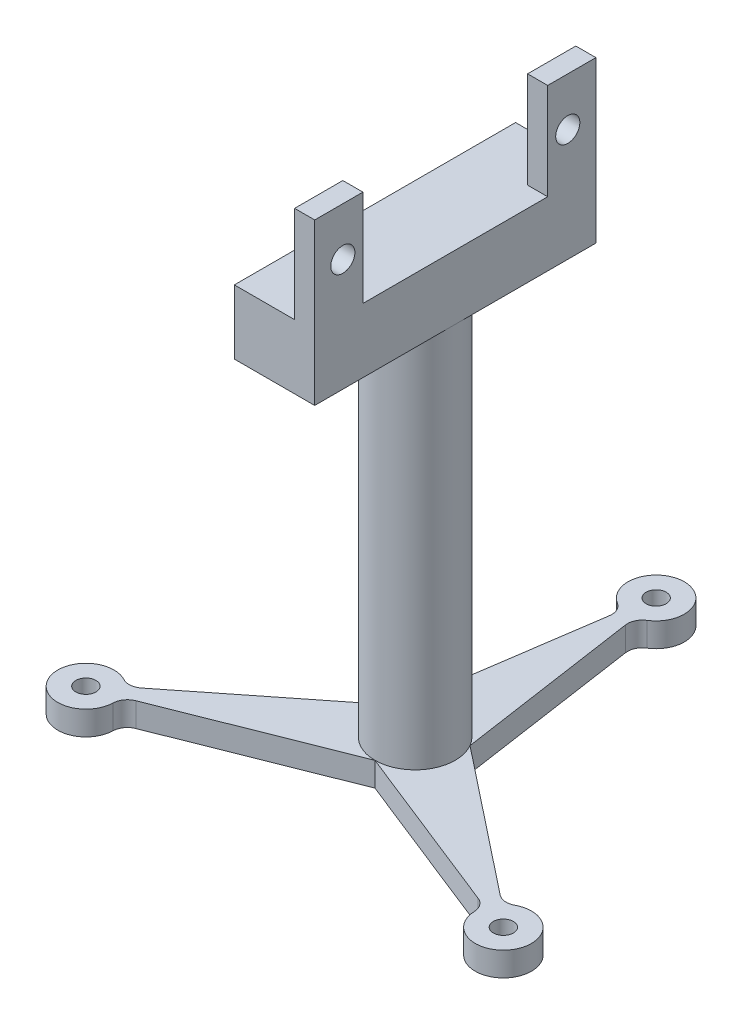
from build123d import *

# Parameters (mm, degrees)
SKETCH1_W                = 5
SKETCH1_H                = 50
SKETCH2_R                = 1.25
BOSS_EXTRUDE1_DEPTH      = 3
CIRPATTERN1_COUNT        = 3
BOSS_EXTRUDE2_DEPTH      = 5
BOSS_EXTRUDE2_DEPTH_BACK = 5
SKETCH3_3_W              = 6
SKETCH3_3_H              = 12
SKETCH3_3_R              = 1.5
BOSS_EXTRUDE3_DEPTH      = 5
SKETCH4_W                = 2.5
SKETCH4_H                = 12
CUT_EXTRUDE1_DEPTH       = 92.488334419


with BuildPart() as part:
    # Sketch1 → Revolve1 (revolve)
    with BuildSketch(Plane.XY):
        with Locations((2.5, 25)):
            Rectangle(SKETCH1_W, SKETCH1_H)
    revolve(axis=Axis((0, 0, 0), (0, 1, 0)))

    # Sketch2 → Boss-Extrude1 (add)
    with BuildSketch(Plane(origin=(0, 0, 0), x_dir=(1, 0, 0), z_dir=(0, 1, 0))):
        with BuildLine():
            Line((-1, 25.183337145), (-4.330127019, 2.5))
            Line((-4.330127019, 2.5), (4.330127019, 2.5))
            Line((4.330127019, 2.5), (1, 25.183337145))
            ThreePointArc((1, 25.183337145), (1.152197325, 26.235023126), (1.855037693, 27.032031813))
            ThreePointArc((1.855037693, 27.032031813), (0, 33.5), (-1.855037693, 27.032031813))
            ThreePointArc((-1.855037693, 27.032031813), (-1.152197325, 26.235023126), (-1, 25.183337145))
        make_face()
        with Locations((0, 30)):
            Circle(SKETCH2_R, mode=Mode.SUBTRACT)
    boss_extrude1 = extrude(amount=BOSS_EXTRUDE1_DEPTH)

    # CirPattern1: Boss-Extrude1 ×3 about axis
    cirpattern1_axis = Axis((0, 50, 0), (0, -1, 0))
    for i in range(1, CIRPATTERN1_COUNT):
        add(boss_extrude1.rotate(cirpattern1_axis, i * 360 / CIRPATTERN1_COUNT))

    # Sketch3 → Boss-Extrude2 (add, two sides: drawn at the far end of the back side and taken through both)
    with BuildSketch(Plane(origin=(0, 0, 0), x_dir=(0, 0, -1), z_dir=(1, 0, 0)).offset(-BOSS_EXTRUDE2_DEPTH_BACK)):
        Polygon((-17.5, 50), (17.5, 50), (17.5, 58), (11.5, 58), (-11.5, 58), (-17.5, 58), align=None)
    extrude(amount=BOSS_EXTRUDE2_DEPTH + BOSS_EXTRUDE2_DEPTH_BACK)

    # Sketch3_3 → Boss-Extrude3 (add)
    # profile 1 of 2: a face of its own
    with BuildSketch(Plane(origin=(0, 0, 0), x_dir=(0, 0, -1), z_dir=(1, 0, 0))):
        with Locations((14.5, 64)):
            Rectangle(SKETCH3_3_W, SKETCH3_3_H)
        with Locations((14, 64)):
            Circle(SKETCH3_3_R, mode=Mode.SUBTRACT)
    # profile 2 of 2: a face of its own
    with BuildSketch(Plane(origin=(0, 0, 0), x_dir=(0, 0, -1), z_dir=(1, 0, 0))):
        with Locations((-14.5, 64)):
            Rectangle(SKETCH3_3_W, SKETCH3_3_H)
        with Locations((-14, 64)):
            Circle(SKETCH3_3_R, mode=Mode.SUBTRACT)
    extrude(amount=BOSS_EXTRUDE3_DEPTH)

    # Sketch4 → Cut-Extrude1 (cut, through all)
    with BuildSketch(Plane.XY.offset(17.5)):
        with Locations((1.25, 64)):
            Rectangle(SKETCH4_W, SKETCH4_H)
    extrude(amount=-CUT_EXTRUDE1_DEPTH, mode=Mode.SUBTRACT)


solid = part.part
